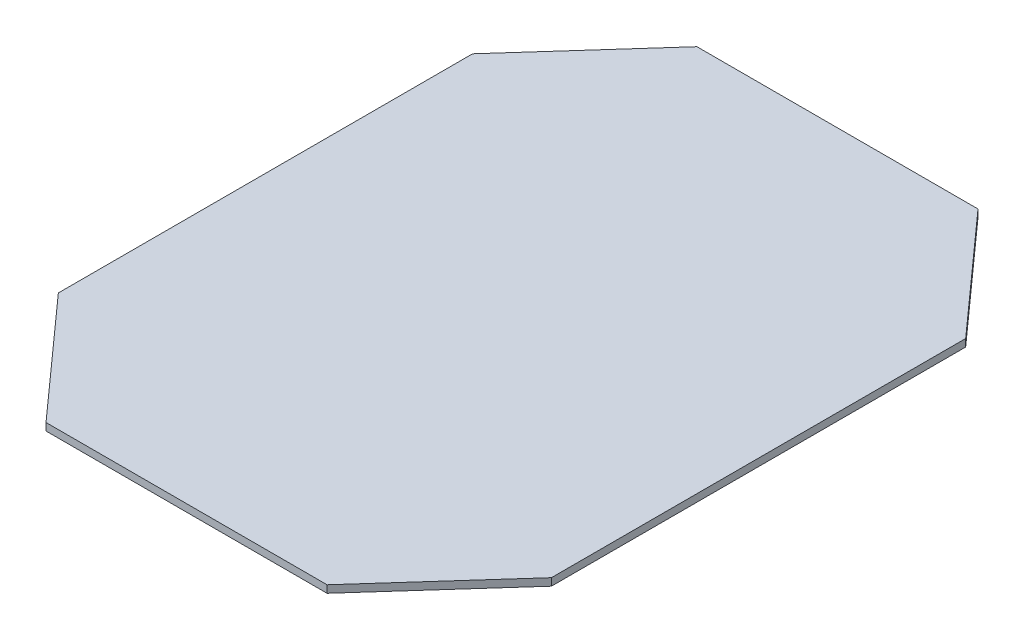
from build123d import *

# Parameters (mm, degrees)
SKETCH1_W           = 100
SKETCH1_H           = 132
BOSS_EXTRUDE1_DEPTH = 1.5
CUT_EXTRUDE1_DEPTH  = 1.5


with BuildPart() as part:
    # Sketch1 → Boss-Extrude1 (new body)
    with BuildSketch(Plane(origin=(0, 0, 0), x_dir=(1, 0, 0), z_dir=(0, 1, 0))):
        with Locations((50, 66)):
            Rectangle(SKETCH1_W, SKETCH1_H)
    extrude(amount=BOSS_EXTRUDE1_DEPTH)

    # Sketch2 → Cut-Extrude1 (cut)
    with BuildSketch(Plane(origin=(0, 1.5, 0), x_dir=(1, 0, 0), z_dir=(0, 1, 0))):
        Polygon((78.5, 132), (100, 108), (126.790697674, 132), (105.290697674, 156), align=None)
        Polygon((-26.790697674, 132), (-5.290697674, 156), (21.5, 132), (0, 108), align=None)
        Polygon((126.790697674, 0), (105.290697674, -24), (78.5, 0), (100, 24), align=None)
        Polygon((0, 24), (-26.790697674, 0), (-5.290697674, -24), (21.5, 0), align=None)
    extrude(amount=-CUT_EXTRUDE1_DEPTH, mode=Mode.SUBTRACT)


solid = part.part
